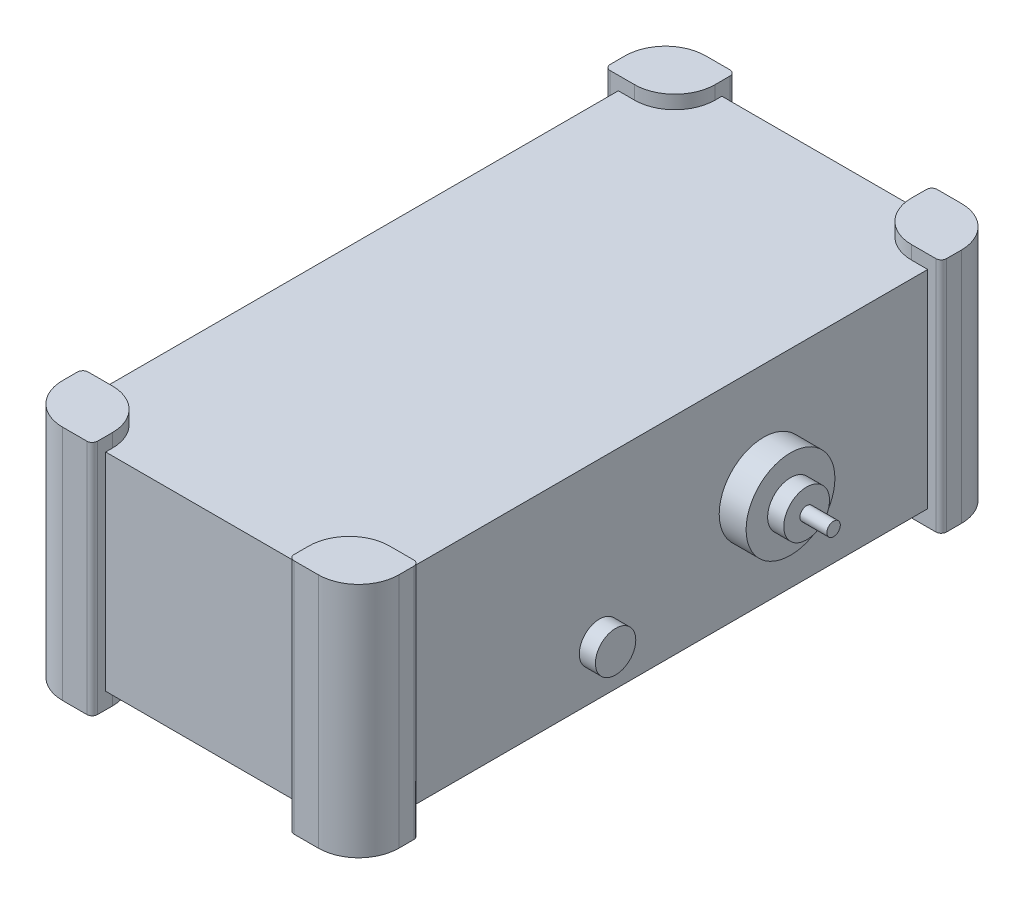
from build123d import *

# Parameters (mm, degrees)
SKETCH1_W                = 115
SKETCH1_H                = 229
BOSS_EXTRUDE1_DEPTH      = 77
BOSS_EXTRUDE3_DEPTH      = 5
BOSS_EXTRUDE3_DEPTH_BACK = 83
SKETCH12_W               = 26
SKETCH12_H               = 22.5
FILLET2_R                = 15
FILLET3_R                = 15
FILLET4_R                = 2
SKETCH13_R               = 7.5
BOSS_EXTRUDE4_DEPTH      = 6
SKETCH13_6_R             = 16.5
BOSS_EXTRUDE5_DEPTH      = 10
SKETCH14_R               = 8.5
BOSS_EXTRUDE6_DEPTH      = 6
SKETCH15_R               = 2.5
BOSS_EXTRUDE7_DEPTH      = 10


with BuildPart() as part:
    # Sketch1 → Boss-Extrude1 (new body)
    with BuildSketch(Plane(origin=(0, 0, 0), x_dir=(1, 0, 0), z_dir=(0, 1, 0))):
        Rectangle(SKETCH1_W, SKETCH1_H)
    extrude(amount=BOSS_EXTRUDE1_DEPTH)

    # Sketch12 → Boss-Extrude3 (add, two sides: drawn at the far end of the back side and taken through both)
    with BuildSketch(Plane(origin=(0, 77, 0), x_dir=(1, 0, 0), z_dir=(0, 1, 0)).offset(-BOSS_EXTRUDE3_DEPTH_BACK)):
        with Locations((-49.5, -108.25)):
            Rectangle(SKETCH12_W, SKETCH12_H)
        with Locations((49.5, -108.25)):
            Rectangle(SKETCH12_W, SKETCH12_H)
        with Locations((49.5, 108.25)):
            Rectangle(SKETCH12_W, SKETCH12_H)
        with Locations((-49.5, 108.25)):
            Rectangle(SKETCH12_W, SKETCH12_H)
    extrude(amount=BOSS_EXTRUDE3_DEPTH + BOSS_EXTRUDE3_DEPTH_BACK)

    # Fillet2
    fillet2_edges = [part.edges().sort_by_distance(p)[0] for p in [
        (-62.5, 38, -119.5),
        (62.5, 38, -119.5),
        (-62.5, 38, 119.5),
        (62.5, 38, 119.5),
    ]]
    fillet(fillet2_edges, radius=FILLET2_R)

    # Fillet3
    fillet3_edges = [part.edges().sort_by_distance(p)[0] for p in [
        (-36.5, -3, -97),
        (36.5, -3, -97),
        (-36.5, -3, 97),
        (36.5, -3, 97),
        (36.5, 79.5, 97),
        (-36.5, 79.5, 97),
        (36.5, 79.5, -97),
        (-36.5, 79.5, -97),
    ]]
    fillet(fillet3_edges, radius=FILLET3_R)

    # Fillet4
    fillet4_edges = [part.edges().sort_by_distance(p)[0] for p in [
        (-62.5, 38, -97),
        (-36.5, 38, -119.5),
        (36.5, 38, -119.5),
        (62.5, 38, -97),
        (62.5, 38, 97),
        (36.5, 38, 119.5),
        (-36.5, 38, 119.5),
        (-62.5, 38, 97),
    ]]
    fillet(fillet4_edges, radius=FILLET4_R)

    # Sketch13 → Boss-Extrude4 (add)
    with BuildSketch(Plane(origin=(57.5, 0, 0), x_dir=(0, 0, -1), z_dir=(1, 0, 0))):
        with Locations((-25, 18)):
            Circle(SKETCH13_R)
    extrude(amount=BOSS_EXTRUDE4_DEPTH)

    # Sketch13_6 → Boss-Extrude5 (add)
    with BuildSketch(Plane(origin=(57.5, 0, 0), x_dir=(0, 0, -1), z_dir=(1, 0, 0))):
        with Locations((36, 37)):
            Circle(SKETCH13_6_R)
    extrude(amount=BOSS_EXTRUDE5_DEPTH)

    # Sketch14 → Boss-Extrude6 (add)
    with BuildSketch(Plane(origin=(67.5, 0, 0), x_dir=(0, 0, -1), z_dir=(1, 0, 0))):
        with Locations((36, 37)):
            Circle(SKETCH14_R)
    extrude(amount=BOSS_EXTRUDE6_DEPTH)

    # Sketch15 → Boss-Extrude7 (add)
    with BuildSketch(Plane(origin=(73.5, 0, 0), x_dir=(0, 0, -1), z_dir=(1, 0, 0))):
        with Locations((36, 37)):
            Circle(SKETCH15_R)
    extrude(amount=BOSS_EXTRUDE7_DEPTH)


solid = part.part
